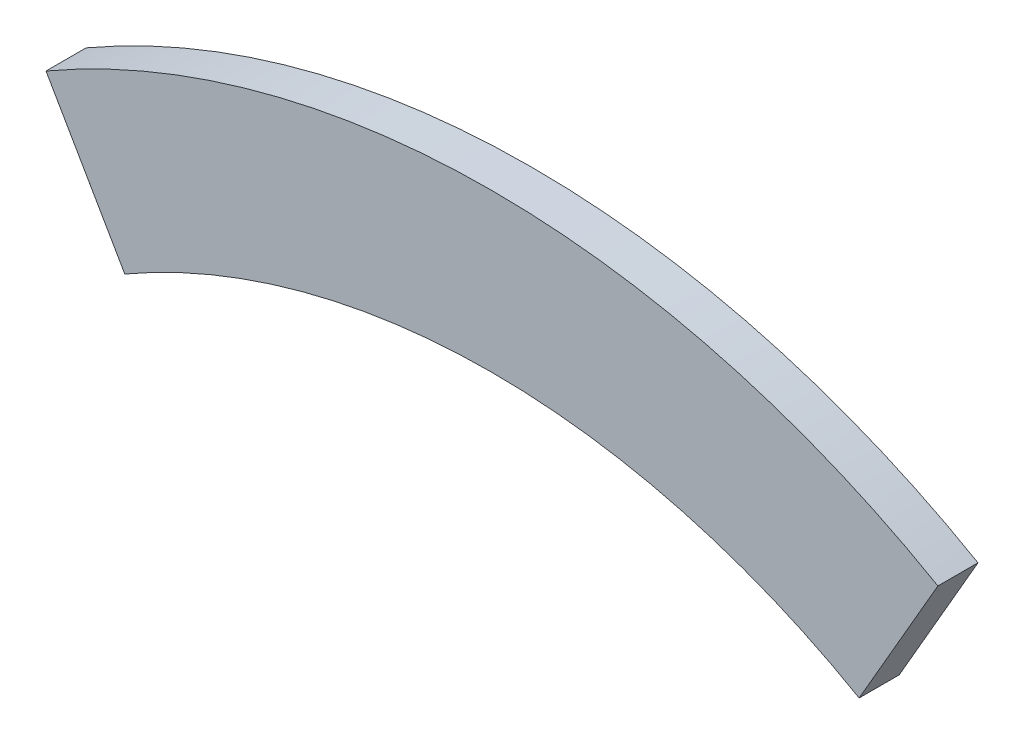
from build123d import *

# Parameters (mm, degrees)
BOSS_EXTRUDE1_DEPTH = 25.4


with BuildPart() as part:
    # Sketch3 → Boss-Extrude1 (new body)
    with BuildSketch(Plane.XY):
        with BuildLine():
            Line((282.575, 489.434256949), (232.664, 402.985869092))
            ThreePointArc((232.664, 402.985869092), (0, 465.328), (-232.664, 402.985869092))
            Line((-232.664, 402.985869092), (-282.575, 489.434256949))
            ThreePointArc((-282.575, 489.434256949), (0, 565.15), (282.575, 489.434256949))
        make_face()
    extrude(amount=BOSS_EXTRUDE1_DEPTH)


solid = part.part
